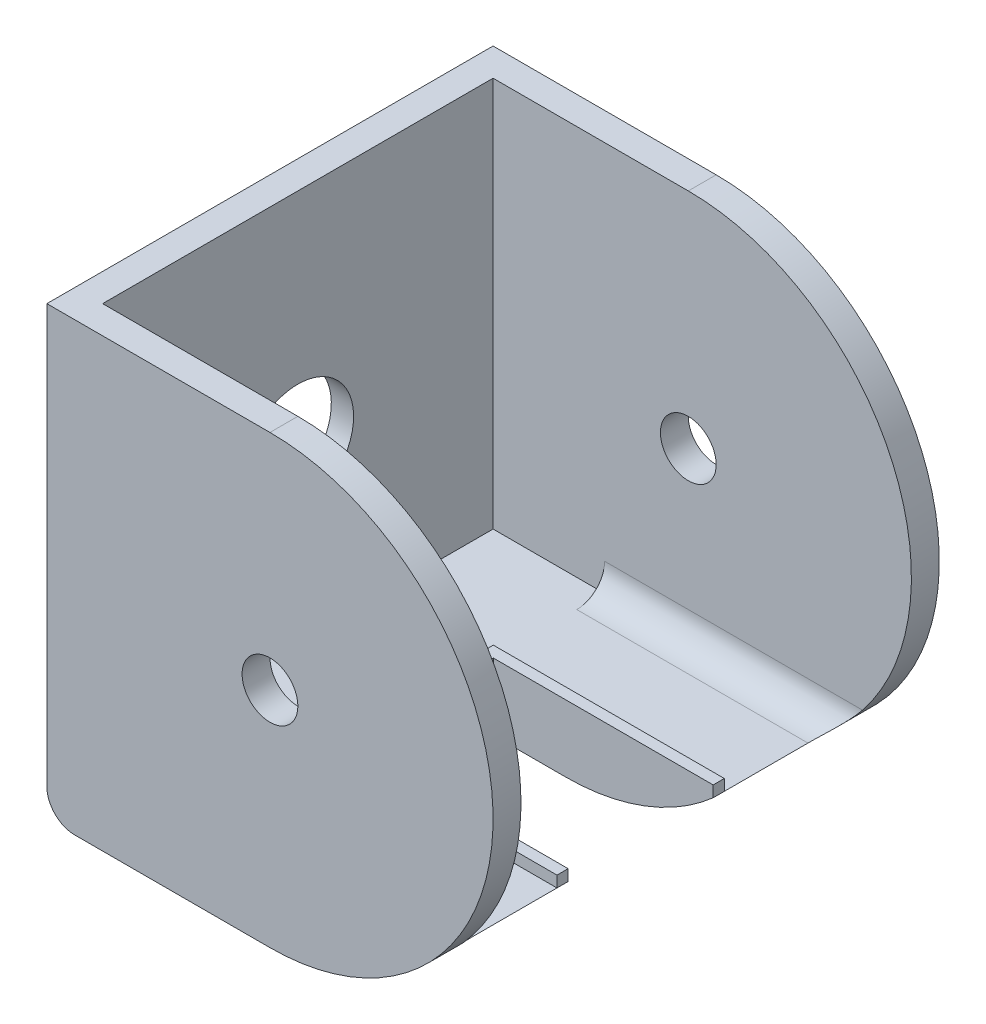
from build123d import *

# Parameters (mm, degrees)
SKETCH1_R           = 4.9999999999999964
BOSS_EXTRUDE1_DEPTH = 5
BOSS_EXTRUDE2_DEPTH = 70
BOSS_EXTRUDE3_DEPTH = 70
CUT_EXTRUDE1_DEPTH  = 5
SKETCH6_R           = 20.000000000000004
CUT_EXTRUDE2_DEPTH  = 1
CUT_EXTRUDE3_DEPTH  = 19.000000000000004
BOSS_EXTRUDE4_DEPTH = 1.9999999999999896
FILLET1_R           = 5
CUT_EXTRUDE4_DEPTH  = 27.00000000000001
BOSS_EXTRUDE5_DEPTH = 2
BOSS_EXTRUDE6_DEPTH = 2


with BuildPart() as part:
    # Sketch1 → Boss-Extrude1 (new body)
    with BuildSketch(Plane.XY):
        with BuildLine():
            Line((-7.704615384615421, -40.00000000000001), (32.295384615384584, -40.00000000000001))
            ThreePointArc((32.295384615384584, -40.00000000000001), (72.29538461538459, 0), (32.29538461538458, 39.99999999999999))
            Line((32.29538461538458, 39.99999999999999), (-7.7046153846154315, 39.99999999999999))
            Line((-7.7046153846154315, 39.99999999999999), (-7.704615384615421, -40.00000000000001))
        make_face()
        with Locations((32.295384615384584, 0)):
            Circle(SKETCH1_R, mode=Mode.SUBTRACT)
    boss_extrude1 = extrude(amount=BOSS_EXTRUDE1_DEPTH)

    # Sketch2 → Boss-Extrude2 (add)
    with BuildSketch(Plane.XY.offset(5)):
        Polygon((-7.7046153846154315, 39.99999999999999), (-2.70461538461543, 39.99999999999999), (-2.7046153846154235, -40.00000000000001), (-7.704615384615421, -40.00000000000001), align=None)
    extrude(amount=BOSS_EXTRUDE2_DEPTH)

    # Mirror1: Boss-Extrude1 across plane
    add(boss_extrude1.mirror(Plane.XY.offset(40)))

    # Sketch4 → Boss-Extrude3 (add)
    with BuildSketch(Plane.XY.offset(5)):
        with BuildLine():
            Line((-2.7046153846154266, -40.00000000000001), (-2.7046153846154266, -30.000000000000007))
            Line((-2.7046153846154266, -30.000000000000007), (43.497251593214216, -30.000000000000007))
            Line((43.497251593214216, -30.000000000000007), (58.7528977260305, -30.000000000000007))
            ThreePointArc((58.7528977260305, -30.000000000000007), (46.43752023911554, -37.41657386773942), (32.295384615384584, -40.00000000000001))
            Line((32.295384615384584, -40.00000000000001), (-2.7046153846154266, -40.00000000000001))
        make_face()
    extrude(amount=BOSS_EXTRUDE3_DEPTH)

    # Sketch5 → Cut-Extrude1 (cut)
    with BuildSketch(Plane.ZY.offset(7.704615384615426)):
        with BuildLine():
            ThreePointArc((50.00000000000001, -1.388e-14), (43.82683432365097, 9.238795325112829), (32.92893218813463, 7.071067811865561))
            Line((32.92893218813452, 7.0710678118654755), (47.071067811865476, -7.071067811865483))
            ThreePointArc((47.0710678118656, -7.0710678118653725), (49.2387953251129, -3.826834323650836), (50.00000000000001, -1.633e-14))
        make_face()
        with BuildLine():
            Line((47.071067811865476, -7.071067811865483), (32.92893218813452, 7.0710678118654755))
            ThreePointArc((32.92893218813463, 7.071067811865561), (32.92893218813454, -7.071067811865502), (47.0710678118656, -7.0710678118653725))
        make_face()
    extrude(amount=-CUT_EXTRUDE1_DEPTH, mode=Mode.SUBTRACT)

    # Sketch6 → Cut-Extrude2 (cut)
    with BuildSketch(Plane.ZY.offset(7.704615384615426)):
        with Locations(Location((40.00000000000001, -1.388e-14, 0), (0, 0, 270))):
            Circle(SKETCH6_R)
    extrude(amount=-CUT_EXTRUDE2_DEPTH, mode=Mode.SUBTRACT)

    # Sketch7 → Cut-Extrude3 (cut)
    with BuildSketch(Plane(origin=(0, -30.000000000000007, 0), x_dir=(1, 0, 0), z_dir=(0, 1, 0))):
        Polygon((58.7528977260305, -53.00000000000001), (58.7528977260305, -40.00000000000001), (58.7528977260305, -27.000000000000004), (19.339689979409883, -27.000000000000007), (19.339689979409883, -53.00000000000001), align=None)
    extrude(amount=-CUT_EXTRUDE3_DEPTH, mode=Mode.SUBTRACT)

    # Sketch8 → Boss-Extrude4 (add)
    with BuildSketch(Plane(origin=(0, -30.000000000000007, 0), x_dir=(1, 0, 0), z_dir=(0, 1, 0))):
        Polygon((58.7528977260305, -53.00000000000001), (19.33968997940988, -53.00000000000001), (19.33968997940988, -27.000000000000007), (58.7528977260305, -27.000000000000004), (58.7528977260305, -25.000000000000007), (56.7528977260305, -25.000000000000007), (17.33968997940988, -25.000000000000007), (17.33968997940988, -55.00000000000001), (58.7528977260305, -55.00000000000001), align=None)
    extrude(amount=BOSS_EXTRUDE4_DEPTH)

    # Fillet1
    fillet1_edges = [part.edges().sort_by_distance(p)[0] for p in [
        (-7.704615384615421, -40.00000000000001, 40),
        (28.024141170707534, -30.000000000000007, 5),
        (28.024141170707537, -30.000000000000007, 75),
    ]]
    fillet(fillet1_edges, radius=FILLET1_R)

    # Sketch9 → Cut-Extrude4 (cut)
    with BuildSketch(Plane(origin=(0, -30.000000000000007, 0), x_dir=(1, 0, 0), z_dir=(0, 1, 0))):
        Polygon((-2.7046153846154266, -69.99999999999999), (-2.70461538461543, -5), (17.295384615384563, -5), (17.295384615384574, -75), (-2.7046153846154266, -75), align=None)
    extrude(amount=CUT_EXTRUDE4_DEPTH, mode=Mode.SUBTRACT)

    # Sketch10 → Boss-Extrude5 (add)
    with BuildSketch(Plane(origin=(0, -30.000000000000007, 0), x_dir=(1, 0, 0), z_dir=(0, 1, 0))):
        Polygon((15.795384615384572, -52.5), (13.795384615384577, -52.5), (-2.704615384615426, -52.5), (-2.7046153846154257, -54.5), (15.79538461538457, -54.5), align=None)
    extrude(amount=BOSS_EXTRUDE5_DEPTH)

    # Sketch11 → Boss-Extrude6 (add)
    with BuildSketch(Plane(origin=(0, -30.000000000000007, 0), x_dir=(1, 0, 0), z_dir=(0, 1, 0))):
        Polygon((-2.704615384615427, -56.849999999999994), (-2.7046153846154266, -58.24999999999999), (15.895384615384575, -58.24999999999999), (15.895384615384579, -75), (17.295384615384574, -75), (17.295384615384574, -69.99999999999999), (17.295384615384574, -56.849999999999994), align=None)
    extrude(amount=BOSS_EXTRUDE6_DEPTH)


solid = part.part
